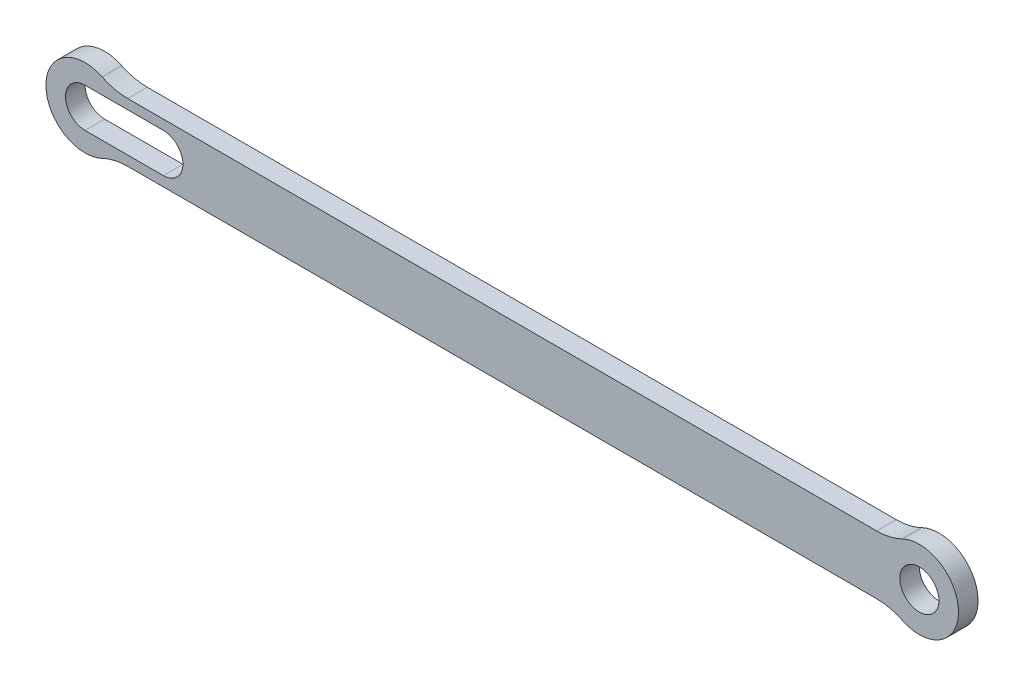
from build123d import *

# Parameters (mm, degrees)
SKETCH1_R           = 5
BOSS_EXTRUDE1_DEPTH = 5


with BuildPart() as part:
    # Sketch1 → Boss-Extrude1 (new body)
    with BuildSketch(Plane.XY):
        with BuildLine():
            Line((-202.232752641, -7.5), (-10.897247359, -7.5))
            ThreePointArc((-10.897247359, -7.5), (-7.543145393, -7.879808483), (-4.358898944, -9))
            ThreePointArc((-4.358898944, -9), (10, 0), (-4.358898944, 9))
            ThreePointArc((-4.358898944, 9), (-7.543145393, 7.879808483), (-10.897247359, 7.5))
            Line((-10.897247359, 7.5), (-202.232752641, 7.5))
            ThreePointArc((-202.232752641, 7.5), (-205.586854607, 7.879808483), (-208.771101056, 9))
            ThreePointArc((-208.771101056, 9), (-223.13, 0), (-208.771101056, -9))
            ThreePointArc((-208.771101056, -9), (-205.586854607, -7.879808483), (-202.232752641, -7.5))
        make_face()
        Circle(SKETCH1_R, mode=Mode.SUBTRACT)
        with BuildLine():
            Line((-213.13, 5), (-193.13, 5))
            ThreePointArc((-193.13, 5), (-188.13, 0), (-193.13, -5))
            Line((-193.13, -5), (-213.13, -5))
            ThreePointArc((-213.13, -5), (-218.13, 0), (-213.13, 5))
        make_face(mode=Mode.SUBTRACT)
    extrude(amount=BOSS_EXTRUDE1_DEPTH)


solid = part.part
